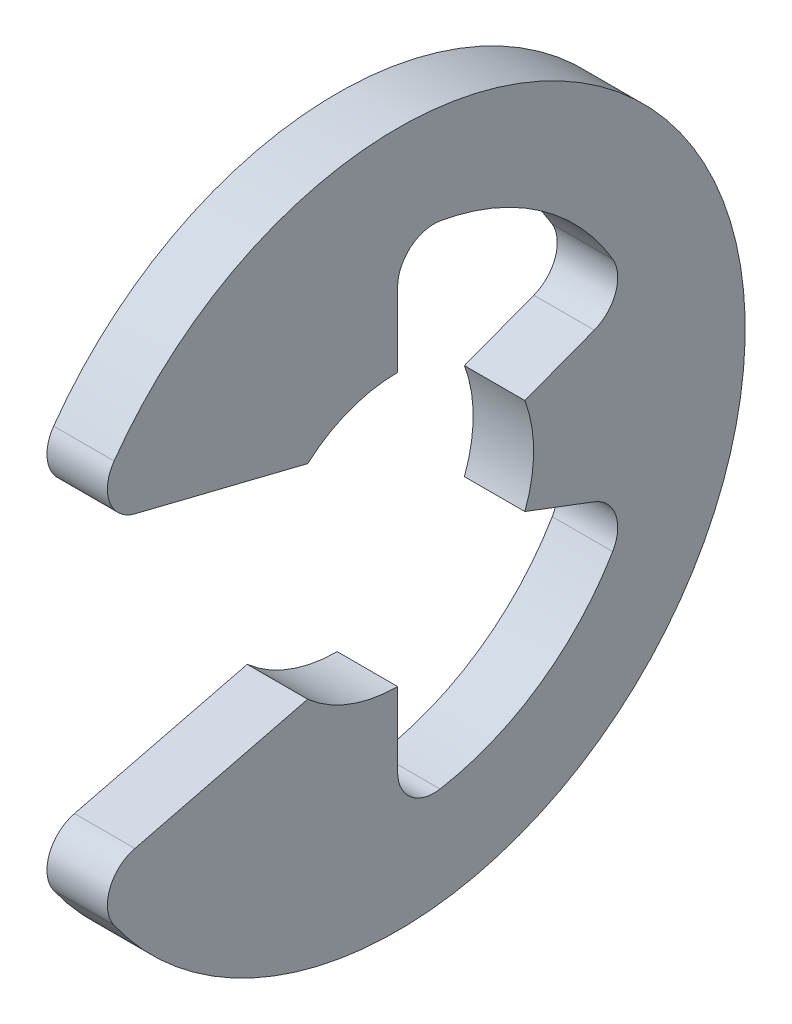
from build123d import *

# Parameters (mm, degrees)
EXTRUDE1_DEPTH = 0.3
FILLET1_R      = 0.36


with BuildPart() as part:
    # Sketch1 → Extrude1 (new body, symmetric)
    with BuildSketch(Plane(origin=(0, 0, 0), x_dir=(0, 0, -1), z_dir=(1, 0, 0))):
        with BuildLine():
            Line((-3.079508789, -1.555353856), (-0.892941067, -1.0125))
            ThreePointArc((-0.892941067, -1.0125), (-0.477297077, -1.262809368), (0, -1.35))
            Line((0, -1.35), (0, -2.477419355))
            ThreePointArc((0, -2.477419355), (1.408480567, -2.038084677), (2.317413607, -0.875900013))
            Line((2.317413607, -0.875900013), (1.262809368, -0.477297077))
            ThreePointArc((1.262809368, -0.477297077), (1.35, 0), (1.262809368, 0.477297077))
            Line((1.262809368, 0.477297077), (2.317413607, 0.875900013))
            ThreePointArc((2.317413607, 0.875900013), (1.408480567, 2.038084677), (0, 2.477419355))
            Line((0, 2.477419355), (0, 1.35))
            ThreePointArc((0, 1.35), (-0.477297077, 1.262809368), (-0.892941067, 1.0125))
            Line((-0.892941067, 1.0125), (-3.079508789, 1.555353856))
            ThreePointArc((-3.079508789, 1.555353856), (3.45, 0), (-3.079508789, -1.555353856))
        make_face()
    extrude(amount=EXTRUDE1_DEPTH, both=True)

    # Fillet1
    fillet1_edges = [part.edges().sort_by_distance(p)[0] for p in [
        (0, -1.555353856, 3.079508789),
        (0, -2.477419355, 0),
        (0, -0.875900013, -2.317413607),
        (0, 0.875900013, -2.317413607),
        (0, 2.477419355, 0),
        (0, 1.555353856, 3.079508789),
    ]]
    fillet(fillet1_edges, radius=FILLET1_R)


solid = part.part
